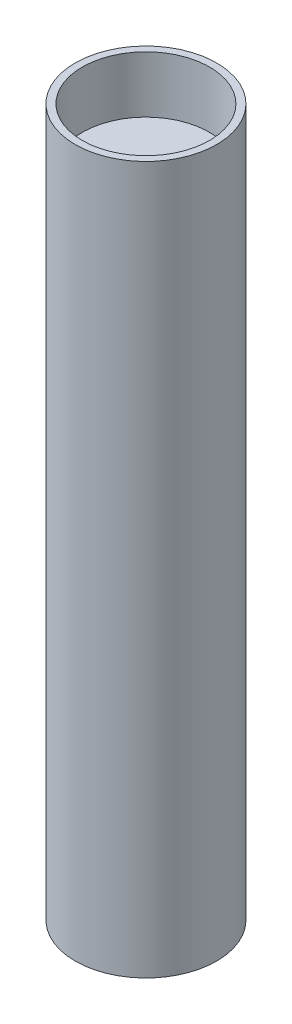
from build123d import *

# Parameters (mm, degrees)
SKETCH_1_R          = 10
EXTRUDE_1_DEPTH     = 100
SKETCH_2_R          = 9
CUT_EXTRUDE_1_DEPTH = 8


with BuildPart() as part:
    # 草图1 → 凸台-拉伸1 (new body)
    with BuildSketch(Plane(origin=(0, 0, 0), x_dir=(1, 0, 0), z_dir=(0, 1, 0))):
        Circle(SKETCH_1_R)
    extrude(amount=EXTRUDE_1_DEPTH)

    # 草图2 → 切除-拉伸1 (cut)
    with BuildSketch(Plane(origin=(0, 100, 0), x_dir=(1, 0, 0), z_dir=(0, 1, 0))):
        Circle(SKETCH_2_R)
    extrude(amount=-CUT_EXTRUDE_1_DEPTH, mode=Mode.SUBTRACT)


solid = part.part
